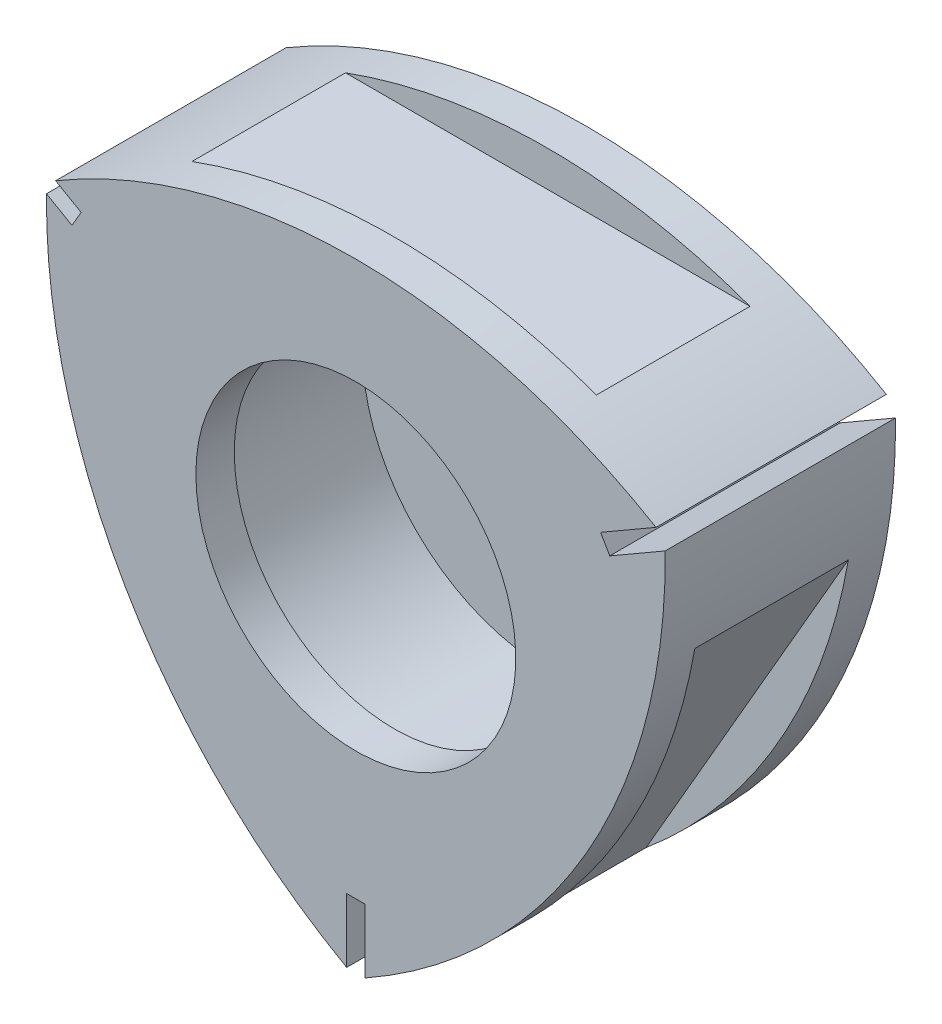
from build123d import *

# Parameters (mm, degrees)
BASE_EXTRUDE_DEPTH           = 18
COMBUSTION_CHAMBER_PROFILE_R = 14.5
CUT_EXTRUDE1_DEPTH           = 12
SKETCH6_R                    = 12.5
CUT_EXTRUDE5_DEPTH           = 3


with BuildPart() as part:
    # rotor profile → Base-Extrude (new body)
    with BuildSketch(Plane.XY):
        with BuildLine():
            Line((-24.173095267, 13.130970823), (-22.181236737, 11.980970764))
            Line((-22.181236737, 11.980970764), (-21.823840171, 12.599999774))
            Line((-21.823840171, 12.599999774), (-21.466443413, 13.219029117))
            Line((-21.466443413, 13.219029117), (-23.458301944, 14.369029176))
            ThreePointArc((-23.458301944, 14.369029176), (-12.161921269, 19.163134144), (0, 20.8))
            ThreePointArc((0, 20.8), (12.161921269, 19.163134144), (23.458301944, 14.369029176))
            Line((23.458301944, 14.369029176), (19.128174925, 11.869029176))
            Line((19.128174925, 11.869029176), (19.485571586, 11.249999999))
            Line((19.485571586, 11.249999999), (19.842968249, 10.630970821))
            Line((19.842968249, 10.630970821), (24.173095268, 13.130970821))
            ThreePointArc((24.173095268, 13.130970821), (22.676721692, 0.95096574), (18.013328561, -10.399999953))
            ThreePointArc((18.013328561, -10.399999953), (10.514800547, -20.114099885), (0.714793524, -27.500000115))
            Line((0.714793524, -27.500000115), (0.714793524, -22.500000115))
            Line((0.714793524, -22.500000115), (0, -22.500000115))
            Line((0, -22.500000115), (-0.714793848, -22.500000115))
            Line((-0.714793848, -22.500000115), (-0.714793848, -27.500000115))
            ThreePointArc((-0.714793848, -27.500000115), (-10.514800813, -20.114099941), (-18.013328717, -10.400000004))
            ThreePointArc((-18.013328717, -10.400000004), (-22.676721717, 0.95096574), (-24.173095267, 13.130970823))
        make_face()
    extrude(amount=BASE_EXTRUDE_DEPTH)

    # combustion chamber profile → Cut-Extrude1 (cut)
    with BuildSketch(Plane(origin=(0, 0, 3), x_dir=(-1, 0, 0), z_dir=(0, 0, -1))):
        Circle(COMBUSTION_CHAMBER_PROFILE_R)
        Polygon((18, 21), (18, 18), (0, 18), (-18, 18), (-18, 21), align=None)
        Polygon((-9.186533479, -26.088457268), (-27.186533479, 5.088457268), (-24.588457268, 6.588457268), (-15.588457268, -9), (-6.588457268, -24.588457268), align=None)
        Polygon((27.186533479, 5.088457268), (9.186533479, -26.088457268), (6.588457268, -24.588457268), (15.588457268, -9), (24.588457268, 6.588457268), align=None)
    extrude(amount=-CUT_EXTRUDE1_DEPTH, mode=Mode.SUBTRACT)

    # Sketch6 → Cut-Extrude5 (cut)
    with BuildSketch(Plane(origin=(0, 0, 18), x_dir=(-1, 0, 0), z_dir=(0, 0, -1))):
        Circle(SKETCH6_R)
    extrude(amount=CUT_EXTRUDE5_DEPTH, mode=Mode.SUBTRACT)


solid = part.part
